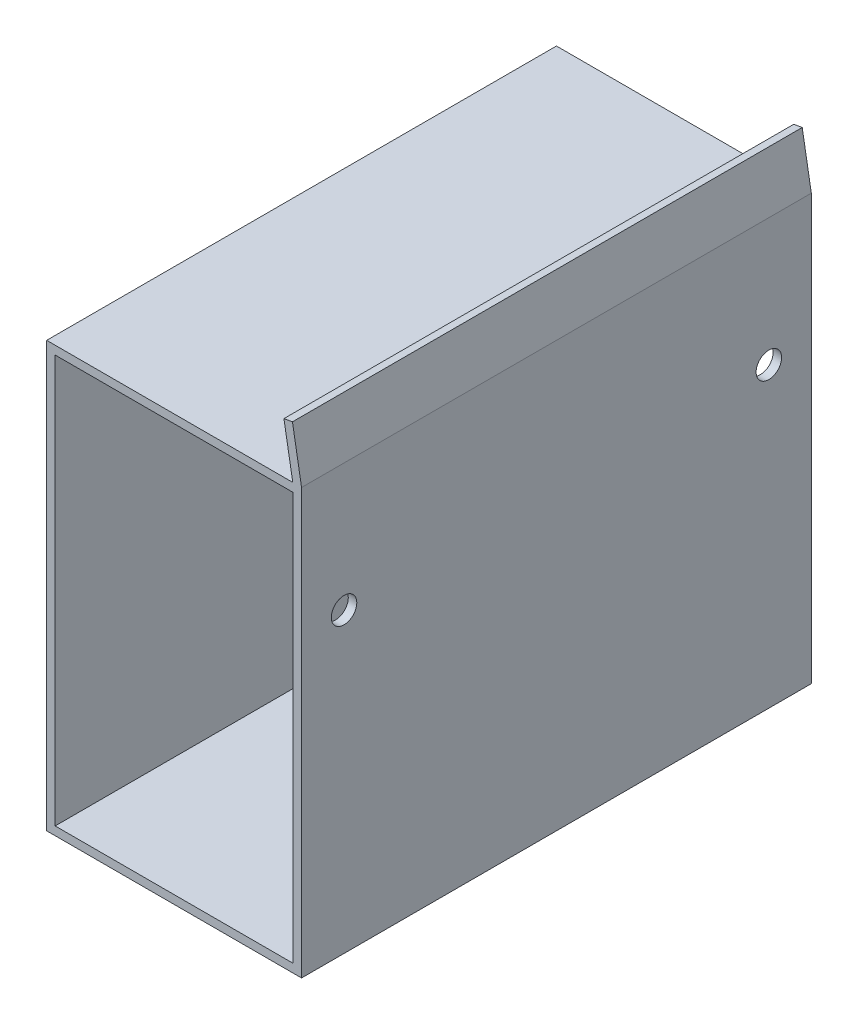
from build123d import *

# Parameters (mm, degrees)
ESBO_O1_W                = 30
ESBO_O1_H                = 50
ESBO_O1_W_2              = 28
ESBO_O1_H_2              = 48
EXTRUS_O_FINA1_DEPTH     = 60
RESSALTO_EXTRUS_O1_DEPTH = 60
ESBO_O3_R                = 1.5
CORTE_EXTRUS_O1_DEPTH    = 10


with BuildPart() as part:
    # Esboço1 → Extrusão-Fina1 (new body)
    with BuildSketch(Plane.XY):
        with Locations((-15, 25)):
            Rectangle(ESBO_O1_W, ESBO_O1_H)
        with Locations((-15, 25)):
            Rectangle(ESBO_O1_W_2, ESBO_O1_H_2, mode=Mode.SUBTRACT)
    extrude(amount=EXTRUS_O_FINA1_DEPTH)

    # Esboço2 → Ressalto-extrusão1 (add, through all)
    with BuildSketch(Plane(origin=(0, 0, 0), x_dir=(-1, 0, 0), z_dir=(0, 0, -1))):
        Polygon((0, 50), (1.071296322, 56.157995634), (2.075314272, 55.983328291), (1.034404539, 50), align=None)
    extrude(amount=-RESSALTO_EXTRUS_O1_DEPTH)

    # Esboço3 → Corte-extrusão1 (cut)
    with BuildSketch(Plane(origin=(0, 0, 0), x_dir=(0, 0, -1), z_dir=(1, 0, 0))):
        with Locations((-55, 35)):
            Circle(ESBO_O3_R)
        with Locations((-5, 35)):
            Circle(ESBO_O3_R)
    extrude(amount=-CORTE_EXTRUS_O1_DEPTH, mode=Mode.SUBTRACT)


solid = part.part
